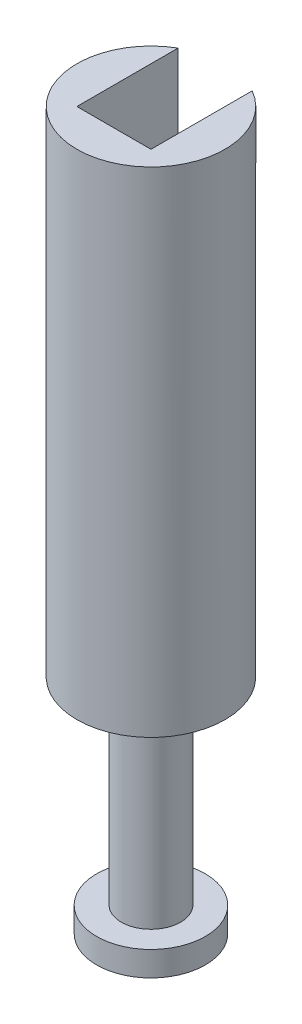
from build123d import *

# Parameters (mm, degrees)
SKETCH1_R           = 15
BOSS_EXTRUDE1_DEPTH = 100
SKETCH3_W           = 15
SKETCH3_H           = 15
CUT_EXTRUDE2_DEPTH  = 75
SKETCH2_R           = 6
BOSS_EXTRUDE2_DEPTH = 40
SKETCH4_R           = 11
BOSS_EXTRUDE3_DEPTH = 5


with BuildPart() as part:
    # Sketch1 → Boss-Extrude1 (new body)
    with BuildSketch(Plane(origin=(0, 0, 0), x_dir=(1, 0, 0), z_dir=(0, 1, 0))):
        Circle(SKETCH1_R)
    extrude(amount=BOSS_EXTRUDE1_DEPTH)

    # Sketch3 → Cut-Extrude2 (cut)
    with BuildSketch(Plane(origin=(0, 100, 0), x_dir=(1, 0, 0), z_dir=(0, 1, 0))):
        Rectangle(SKETCH3_W, SKETCH3_H)
        with BuildLine():
            Line((-7.5, 12.990381057), (-7.5, 7.5))
            Line((-7.5, 7.5), (7.5, 7.5))
            Line((7.5, 7.5), (7.5, 12.990381057))
            ThreePointArc((7.5, 12.990381057), (3.882285677, 14.488887394), (0, 15))
            ThreePointArc((0, 15), (-3.882285677, 14.488887394), (-7.5, 12.990381057))
        make_face()
    extrude(amount=-CUT_EXTRUDE2_DEPTH, mode=Mode.SUBTRACT)

    # Sketch2 → Boss-Extrude2 (add)
    with BuildSketch(Plane.XZ):
        Circle(SKETCH2_R)
    extrude(amount=BOSS_EXTRUDE2_DEPTH)

    # Sketch4 → Boss-Extrude3 (add)
    with BuildSketch(Plane(origin=(0, -40, 0), x_dir=(-1, 0, 0), z_dir=(0, -1, 0))):
        Circle(SKETCH4_R)
    extrude(amount=BOSS_EXTRUDE3_DEPTH)


solid = part.part
